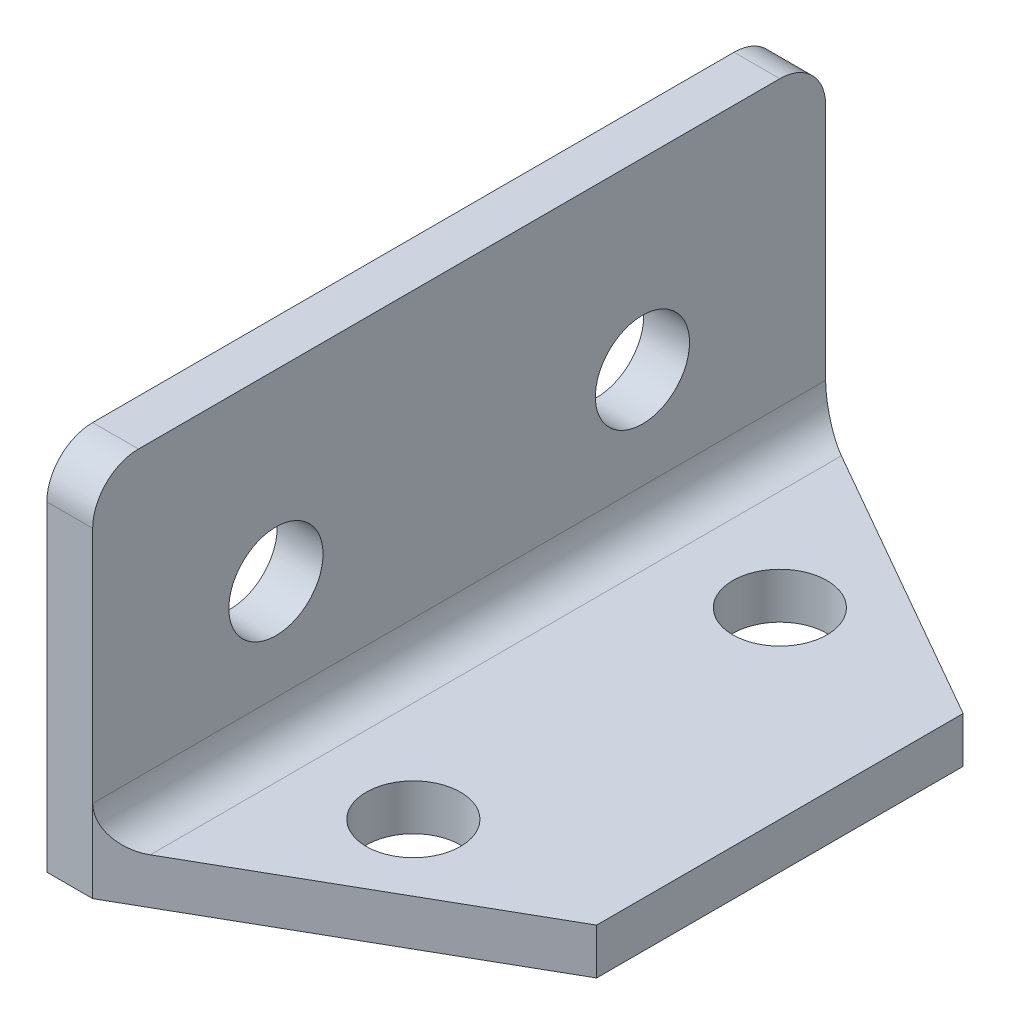
from build123d import *

# Parameters (mm, degrees)
SKETCH1_W               = 25.4
SKETCH1_H               = 50.8
SKETCH1_R               = 3.2639
BOSS_EXTRUDE1_DEPTH     = 3.175
SKETCH2_W               = 3.175
SKETCH2_H               = 50.8
BOSS_EXTRUDE2_DEPTH     = 22.225
SKETCH3_R               = 3.2639
CUT_EXTRUDE1_DEPTH      = 22.225
FILLET2_R               = 2.54
CUT_EXTRUDE3_DEPTH      = 23.225
CUT_EXTRUDE3_DEPTH_BACK = 4.175
FILLET3_R               = 3.175
FILLET4_R               = 3.175


with BuildPart() as part:
    # Sketch1 → Boss-Extrude1 (new body)
    with BuildSketch(Plane(origin=(0, 0, 0), x_dir=(1, 0, 0), z_dir=(0, 1, 0))):
        with Locations((12.7, 25.4)):
            Rectangle(SKETCH1_W, SKETCH1_H)
        with Locations((12.7, 38.1)):
            Circle(SKETCH1_R, mode=Mode.SUBTRACT)
        with Locations((12.7, 12.7)):
            Circle(SKETCH1_R, mode=Mode.SUBTRACT)
    extrude(amount=BOSS_EXTRUDE1_DEPTH)

    # Sketch2 → Boss-Extrude2 (add)
    with BuildSketch(Plane(origin=(0, 3.175, 0), x_dir=(1, 0, 0), z_dir=(0, 1, 0))):
        with Locations((1.5875, 25.4)):
            Rectangle(SKETCH2_W, SKETCH2_H)
    extrude(amount=BOSS_EXTRUDE2_DEPTH)

    # Sketch3 → Cut-Extrude1 (cut)
    with BuildSketch(Plane(origin=(3.175, 0, 0), x_dir=(0, 0, -1), z_dir=(1, 0, 0))):
        with Locations((12.7, 12.7)):
            Circle(SKETCH3_R)
        with Locations((38.1, 12.7)):
            Circle(SKETCH3_R)
    extrude(amount=-CUT_EXTRUDE1_DEPTH, mode=Mode.SUBTRACT)

    # Fillet2
    fillet2_edges = [part.edges().sort_by_distance(p)[0] for p in [
        (3.175, 3.175, -25.4),
    ]]
    fillet(fillet2_edges, radius=FILLET2_R)

    # Sketch4 → Cut-Extrude3 (cut, two sides)
    with BuildSketch(Plane(origin=(0, 3.175, 0), x_dir=(1, 0, 0), z_dir=(0, 1, 0))) as cut_extrude3_sk:
        Polygon((25.4, 0), (25.4, 12.7), (3.175, 0), align=None)
        Polygon((25.4, 50.8), (25.4, 38.1), (3.175, 50.8), align=None)
    extrude(amount=CUT_EXTRUDE3_DEPTH, mode=Mode.SUBTRACT)
    extrude(cut_extrude3_sk.sketch, amount=-CUT_EXTRUDE3_DEPTH_BACK, mode=Mode.SUBTRACT)

    # Fillet3
    fillet3_edges = [part.edges().sort_by_distance(p)[0] for p in [
        (1.5875, 25.4, 0),
    ]]
    fillet(fillet3_edges, radius=FILLET3_R)

    # Fillet4
    fillet4_edges = [part.edges().sort_by_distance(p)[0] for p in [
        (1.5875, 25.4, -50.8),
    ]]
    fillet(fillet4_edges, radius=FILLET4_R)


solid = part.part
